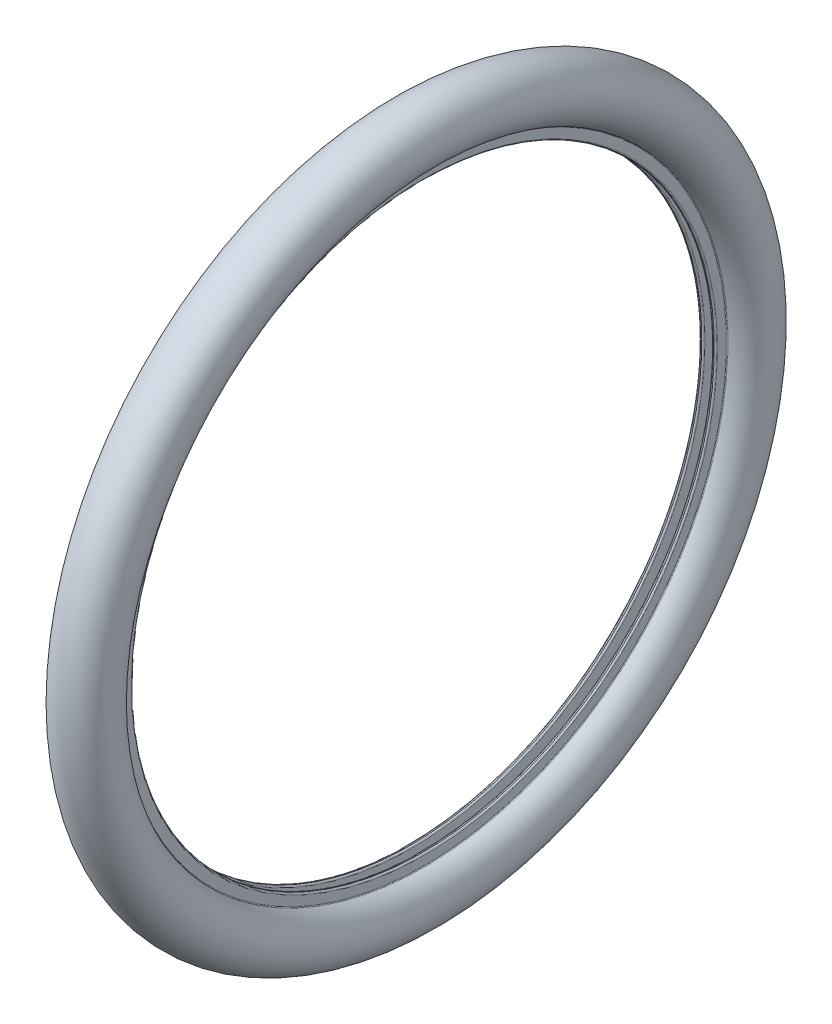
from build123d import *


with BuildPart() as part:
    # Эскиз1 → Повернуть1 (revolve)
    with BuildSketch(Plane.XY):
        with BuildLine():
            Line((-8, 292.218099488), (-8, 283.5))
            ThreePointArc((-8, 283.5), (-7.560660172, 282.439339828), (-6.5, 282))
            Line((-6.5, 282), (-5.5, 282))
            ThreePointArc((-5.5, 282), (-4.439339828, 282.439339828), (-4, 283.5))
            Line((-4, 283.5), (-4, 297.906109056))
            ThreePointArc((-4, 297.906109056), (-5.025126266, 300.38098279), (-7.5, 301.406109056))
            Line((-7.5, 301.406109056), (-8, 301.406109056))
            ThreePointArc((-8, 301.406109056), (0, 338.6895283), (8, 301.406109056))
            Line((8, 301.406109056), (7.5, 301.406109056))
            ThreePointArc((7.5, 301.406109056), (5.025126266, 300.38098279), (4, 297.906109056))
            Line((4, 297.906109056), (4, 283.5))
            ThreePointArc((4, 283.5), (4.439339828, 282.439339828), (5.5, 282))
            Line((5.5, 282), (6.5, 282))
            ThreePointArc((6.5, 282), (7.560660172, 282.439339828), (8, 283.5))
            Line((8, 283.5), (8, 292.218099488))
            ThreePointArc((8, 292.218099488), (8.171178588, 292.747029702), (8.619798245, 293.075373551))
            ThreePointArc((8.619798245, 293.075373551), (0, 346.6895283), (-8.619798245, 293.075373551))
            ThreePointArc((-8.619798245, 293.075373551), (-8.171178588, 292.747029702), (-8, 292.218099488))
        make_face()
    revolve(axis=Axis((-25, 0, 0), (1, 0, 0)))


solid = part.part
